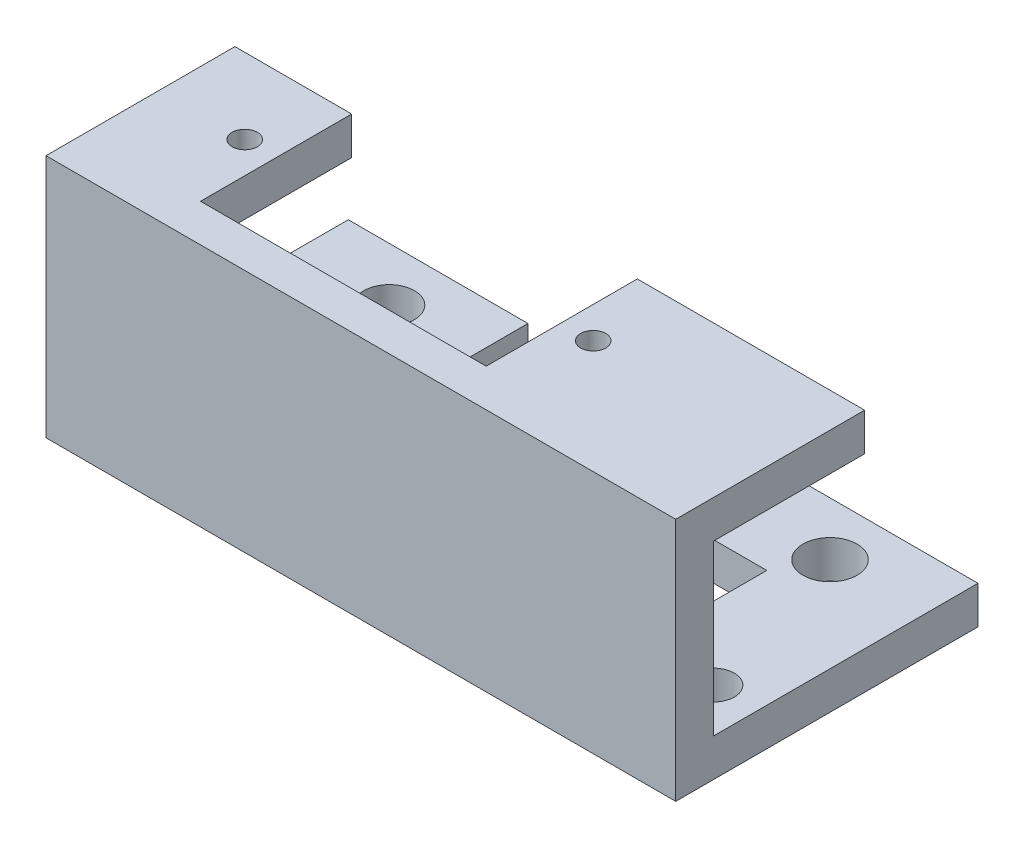
from build123d import *

# Parameters (mm, degrees)
SKETCH_1_W          = 50
SKETCH_1_H          = 19.4
EXTRUDE_1_DEPTH     = 3
SKETCH_2_W          = 18.05
SKETCH_2_H          = 3
SKETCH_2_W_2        = 9.27
EXTRUDE_3_DEPTH     = 12
SKETCH_5_R          = 1
CUT_EXTRUDE_1_DEPTH = 4
SKETCH_6_W          = 9.27
SKETCH_6_H          = 2.996679997
EXTRUDE_5_DEPTH     = 21
SKETCH_9_W          = 7.5
SKETCH_9_H          = 2.996679997
EXTRUDE_6_DEPTH     = 5
SKETCH_10_W         = 7.5
SKETCH_10_H         = 2.996679997
EXTRUDE_7_DEPTH     = 5
SKETCH_11_R         = 2.15
SKETCH_11_R_2       = 1.65
CUT_EXTRUDE_3_DEPTH = 5
SKETCH_12_R         = 2
SKETCH_12_R_2       = 1.65
CUT_EXTRUDE_4_DEPTH = 5


with BuildPart() as part:
    # 草图1 → 凸台-拉伸1 (new body)
    with BuildSketch(Plane.XY):
        with Locations((25, 9.7)):
            Rectangle(SKETCH_1_W, SKETCH_1_H)
    extrude(amount=EXTRUDE_1_DEPTH)

    # 草图2 → 凸台-拉伸3 (add)
    with BuildSketch(Plane(origin=(0, 0, 0), x_dir=(-1, 0, 0), z_dir=(0, 0, -1))):
        with Locations((-40.975, 17.9)):
            Rectangle(SKETCH_2_W, SKETCH_2_H)
        with Locations((-4.635, 17.9)):
            Rectangle(SKETCH_2_W_2, SKETCH_2_H)
    extrude(amount=EXTRUDE_3_DEPTH)

    # 草图5 → 切除-拉伸1 (cut)
    with BuildSketch(Plane(origin=(0, 19.4, 0), x_dir=(1, 0, 0), z_dir=(0, 1, 0))):
        with Locations((34.45, 6)):
            Circle(SKETCH_5_R)
        with Locations((6.78, 6)):
            Circle(SKETCH_5_R)
    extrude(amount=-CUT_EXTRUDE_1_DEPTH, mode=Mode.SUBTRACT)

    # 草图6 → 凸台-拉伸5 (add)
    with BuildSketch(Plane(origin=(0, 0, 0), x_dir=(-1, 0, 0), z_dir=(0, 0, -1))):
        with Locations((-45.365, 1.498339999)):
            Rectangle(SKETCH_6_W, SKETCH_6_H)
        with Locations((-4.635, 1.498339999)):
            Rectangle(SKETCH_6_W, SKETCH_6_H)
    extrude(amount=EXTRUDE_5_DEPTH)

    # 草图9 → 凸台-拉伸6 (add)
    with BuildSketch(Plane(origin=(9.27, 0, 0), x_dir=(0, 0, -1), z_dir=(1, 0, 0))):
        with Locations((17.25, 1.498339999)):
            Rectangle(SKETCH_9_W, SKETCH_9_H)
    extrude(amount=EXTRUDE_6_DEPTH)

    # 草图10 → 凸台-拉伸7 (add)
    with BuildSketch(Plane.ZY.offset(-40.73)):
        with Locations((-17.25, 1.498339999)):
            Rectangle(SKETCH_10_W, SKETCH_10_H)
    extrude(amount=EXTRUDE_7_DEPTH)

    # 草图11 → 切除-拉伸3 (cut)
    with BuildSketch(Plane(origin=(0, 2.996679997, 0), x_dir=(1, 0, 0), z_dir=(0, 1, 0))):
        with Locations((42.5, 16.75)):
            Circle(SKETCH_11_R)
        with Locations((46.5, 3.5)):
            Circle(SKETCH_11_R_2)
    extrude(amount=-CUT_EXTRUDE_3_DEPTH, mode=Mode.SUBTRACT)

    # 草图12 → 切除-拉伸4 (cut)
    with BuildSketch(Plane(origin=(0, 2.996679997, 0), x_dir=(1, 0, 0), z_dir=(0, 1, 0))):
        with Locations((7.5, 16.75)):
            Circle(SKETCH_12_R)
        with Locations((3.5, 3.5)):
            Circle(SKETCH_12_R_2)
    extrude(amount=-CUT_EXTRUDE_4_DEPTH, mode=Mode.SUBTRACT)


solid = part.part
